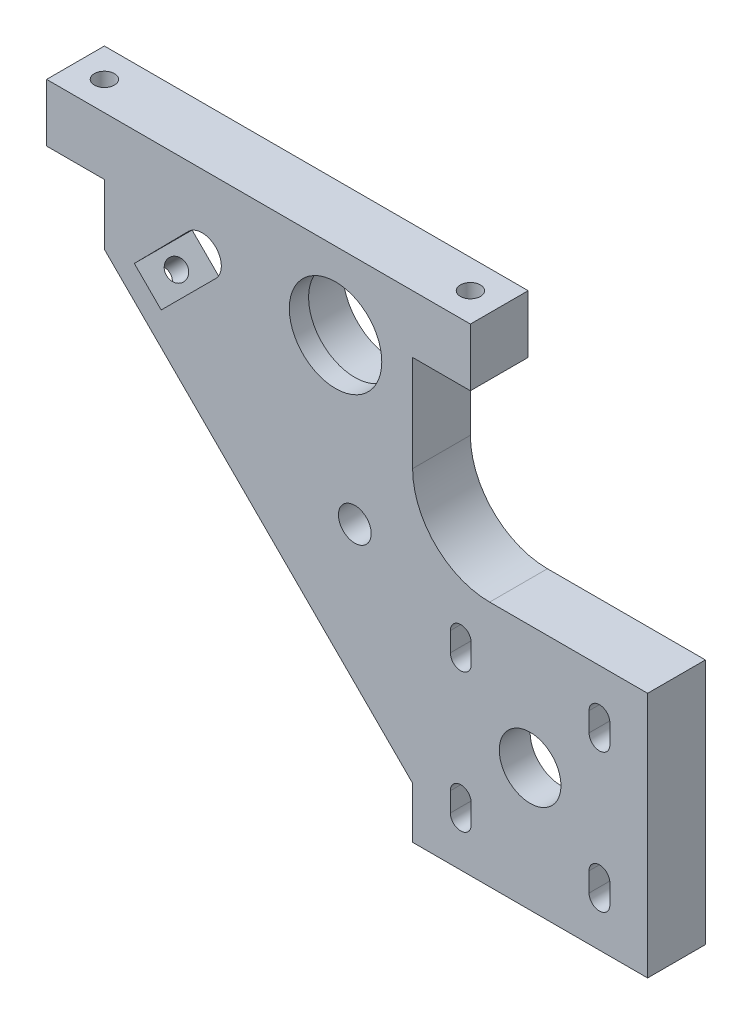
from build123d import *

# Parameters (mm, degrees)
SKETCH_1_R          = 12
SKETCH_1_R_2        = 4.25
SKETCH_1_R_3        = 8
EXTRUDE_1_DEPTH     = 15
SKETCH_2_R          = 13.1
CUT_EXTRUDE_1_DEPTH = 10
CUT_EXTRUDE_2_REACH = 176.739
SKETCH_3_R          = 2.6
SKETCH_5_R          = 2.6
CUT_EXTRUDE_3_DEPTH = 10
SKETCH_6_W          = 50
SKETCH_6_H          = 50
CUT_EXTRUDE_4_DEPTH = 7
FILLET_1_R          = 2
FILLET_2_R          = 20


with BuildPart() as part:
    # 草图1 → 凸台-拉伸1 (new body)
    with BuildSketch(Plane.XY):
        Polygon((-33.800989673, 26.429197467), (-27.44059998, 26.429197467), (-18.800989673, 26.429197467), (-18.800989673, 10.718519348), (61.199010327, -69.281480652), (61.199010327, -82.570802533), (122.199010327, -82.570802533), (122.199010327, -18.570802533), (61.199010327, -18.570802533), (61.199010327, 26.429197467), (76.199010327, 26.429197467), (76.199010327, 41.429197467), (56.199010327, 41.429197467), (-33.800989673, 41.429197467), align=None)
        with Locations((41.199010327, 21.429197467)):
            Circle(SKETCH_1_R, mode=Mode.SUBTRACT)
        with Locations((46.199010327, -18.570802533)):
            Circle(SKETCH_1_R_2, mode=Mode.SUBTRACT)
        with Locations((91.699010327, -50.570802533)):
            Circle(SKETCH_1_R_3, mode=Mode.SUBTRACT)
        with BuildLine():
            Line((-11.034973369, 11.437784418), (2.9923212, 25.648765615))
            ThreePointArc((2.9923212, 25.648765615), (10.086164278, 25.671985824), (10.063536665, 18.57814083))
            Line((10.063536665, 18.57814083), (-4.055896558, 4.458707607))
            Line((-4.055896558, 4.458707607), (-11.034973369, 11.437784418))
        make_face(mode=Mode.SUBTRACT)
        with BuildLine():
            Line((106.999010327, -30.070802533), (106.999010327, -35.070802533))
            ThreePointArc((106.999010327, -35.070802533), (109.699010327, -37.770802533), (112.399010327, -35.070802533))
            Line((112.399010327, -35.070802533), (112.399010327, -30.070802533))
            ThreePointArc((112.399010327, -30.070802533), (109.699010327, -27.370802533), (106.999010327, -30.070802533))
        make_face(mode=Mode.SUBTRACT)
        with BuildLine():
            Line((70.999010327, -30.070802533), (70.999010327, -35.070802533))
            ThreePointArc((70.999010327, -35.070802533), (73.699010327, -37.770802533), (76.399010327, -35.070802533))
            Line((76.399010327, -35.070802533), (76.399010327, -30.070802533))
            ThreePointArc((76.399010327, -30.070802533), (73.699010327, -27.370802533), (70.999010327, -30.070802533))
        make_face(mode=Mode.SUBTRACT)
        with BuildLine():
            Line((76.399010327, -71.070802533), (76.399010327, -66.070802533))
            ThreePointArc((76.399010327, -66.070802533), (73.699010327, -63.370802533), (70.999010327, -66.070802533))
            Line((70.999010327, -66.070802533), (70.999010327, -71.070802533))
            ThreePointArc((70.999010327, -71.070802533), (73.699010327, -73.770802533), (76.399010327, -71.070802533))
        make_face(mode=Mode.SUBTRACT)
        with BuildLine():
            Line((112.399010327, -71.070802533), (112.399010327, -66.070802533))
            ThreePointArc((112.399010327, -66.070802533), (109.699010327, -63.370802533), (106.999010327, -66.070802533))
            Line((106.999010327, -66.070802533), (106.999010327, -71.070802533))
            ThreePointArc((106.999010327, -71.070802533), (109.699010327, -73.770802533), (112.399010327, -71.070802533))
        make_face(mode=Mode.SUBTRACT)
    extrude(amount=EXTRUDE_1_DEPTH)

    # 草图2 → 切除-拉伸1 (cut)
    with BuildSketch(Plane(origin=(0, 0, 0), x_dir=(-1, 0, 0), z_dir=(0, 0, -1))):
        with Locations((-41.199010327, 21.429197467)):
            Circle(SKETCH_2_R)
    extrude(amount=-CUT_EXTRUDE_1_DEPTH, mode=Mode.SUBTRACT)

    # 草图3 → 切除-拉伸2 (cut, up to next)
    with BuildSketch(Plane(origin=(0, 41.429197467, 0), x_dir=(1, 0, 0), z_dir=(0, 1, 0)), mode=Mode.PRIVATE) as cut_extrude_2_sk1:
        with Locations((-26.300989673, -7.5)):
            Circle(SKETCH_3_R)
    cut_extrude_2_tool1 = extrude(cut_extrude_2_sk1.sketch, amount=-CUT_EXTRUDE_2_REACH, mode=Mode.PRIVATE) & part.part
    # 草图3 → 切除-拉伸2 (cut, up to next)
    with BuildSketch(Plane(origin=(0, 41.429197467, 0), x_dir=(1, 0, 0), z_dir=(0, 1, 0)), mode=Mode.PRIVATE) as cut_extrude_2_sk2:
        with Locations((68.699010327, -7.5)):
            Circle(SKETCH_3_R)
    cut_extrude_2_tool2 = extrude(cut_extrude_2_sk2.sketch, amount=-CUT_EXTRUDE_2_REACH, mode=Mode.PRIVATE) & part.part
    add(cut_extrude_2_tool1.solids().sort_by_distance((-26.30099, 41.429197, 7.5))[0], mode=Mode.SUBTRACT)
    add(cut_extrude_2_tool2.solids().sort_by_distance((68.69901, 41.429197, 7.5))[0], mode=Mode.SUBTRACT)

    # 草图5 → 切除-拉伸3 (cut)
    with BuildSketch(Plane(origin=(-4.041235162, -4.041235162, 0), x_dir=(0, 0, 1), z_dir=(-0.7071067811865485, -0.7071067811865467, 0))):
        with Locations((7.5, 11.023445006)):
            Circle(SKETCH_5_R)
    extrude(amount=-CUT_EXTRUDE_3_DEPTH, mode=Mode.SUBTRACT)

    # 草图6 → 切除-拉伸4 (cut)
    with BuildSketch(Plane(origin=(0, 0, 0), x_dir=(-1, 0, 0), z_dir=(0, 0, -1))):
        with Locations((-91.699010327, -50.570802533)):
            Rectangle(SKETCH_6_W, SKETCH_6_H)
    extrude(amount=-CUT_EXTRUDE_4_DEPTH, mode=Mode.SUBTRACT)

    # 圆角1
    fillet_1_edges = [part.edges().sort_by_distance(p)[0] for p in [
        (91.699010327, -75.570802533, 7),
        (116.699010327, -50.570802533, 7),
        (66.699010327, -50.570802533, 7),
        (91.699010327, -25.570802533, 7),
    ]]
    fillet(fillet_1_edges, radius=FILLET_1_R)

    # 圆角2
    fillet_2_edges = [part.edges().sort_by_distance(p)[0] for p in [
        (61.199010327, -18.570802533, 7.5),
    ]]
    fillet(fillet_2_edges, radius=FILLET_2_R)


solid = part.part
